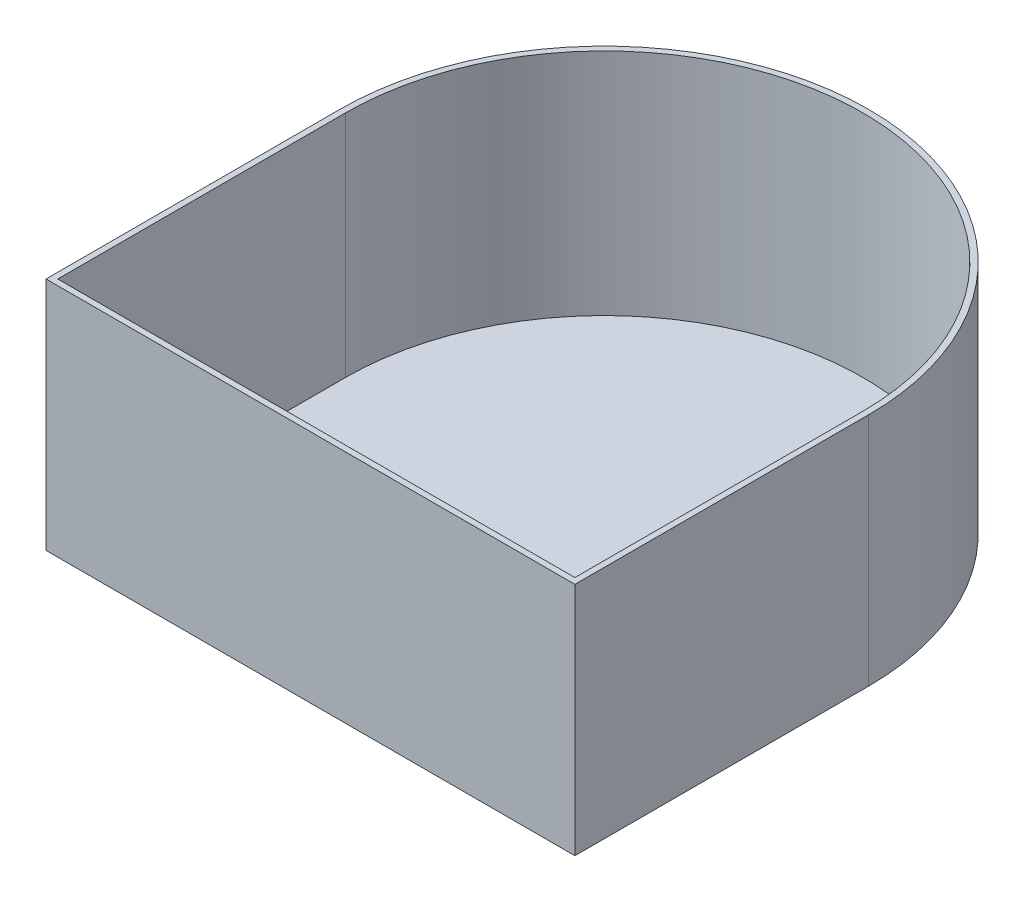
from build123d import *

# Parameters (mm, degrees)
BOSS_EXTRUDE1_DEPTH = 40
SHELL1_T            = -1


with BuildPart() as part:
    # Sketch1 → Boss-Extrude1 (new body)
    with BuildSketch(Plane(origin=(0, 0, 0), x_dir=(1, 0, 0), z_dir=(0, 1, 0))):
        with BuildLine():
            Line((-45, 0), (-45, -50))
            Line((-45, -50), (45, -50))
            Line((45, -50), (45, 0))
            ThreePointArc((45, 0), (0, 45), (-45, 0))
        make_face()
    extrude(amount=BOSS_EXTRUDE1_DEPTH)

    # Shell1
    shell1_openings = [part.faces().sort_by_distance(p)[0] for p in [
        (0, 40, 13.75),
    ]]
    offset(amount=SHELL1_T, openings=shell1_openings, kind=Kind.INTERSECTION)


solid = part.part
